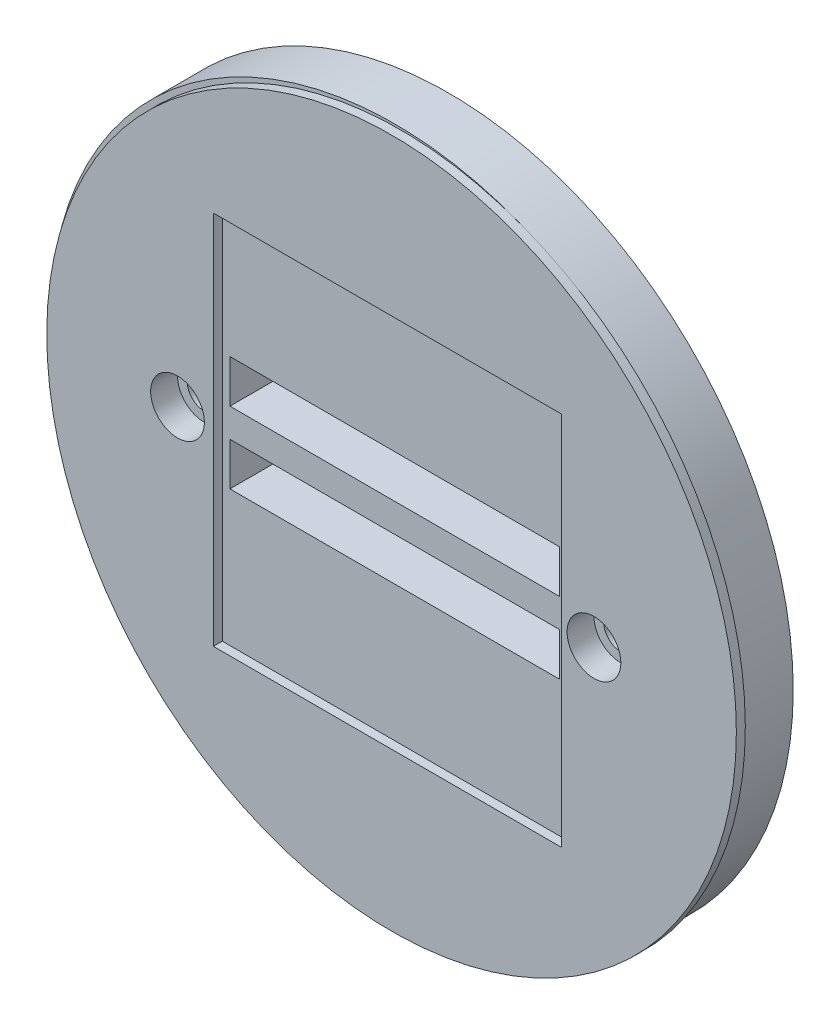
from build123d import *

# Parameters (mm, degrees)
SKETCH1_R                  = 38.5
SKETCH1_R_2                = 1.925
SKETCH1_W                  = 36.8
SKETCH1_H                  = 4.8
MAIN_FLANGE_COUPLING_DEPTH = 6
SKETCH2_R                  = 38.5
SKETCH2_R_2                = 1.7
SKETCH2_W                  = 38.9
SKETCH2_H                  = 41.9
BOSS_EXTRUDE1_DEPTH        = 1
SKETCH3_R                  = 3
CUT_EXTRUDE1_DEPTH         = 3


with BuildPart() as part:
    # Sketch1 → Main Flange Coupling (new body)
    with BuildSketch(Plane.XY):
        Circle(SKETCH1_R)
        with Locations((-23.25, 0)):
            Circle(SKETCH1_R_2, mode=Mode.SUBTRACT)
        with Locations((23.25, 0)):
            Circle(SKETCH1_R_2, mode=Mode.SUBTRACT)
        with Locations((0, 4.4)):
            Rectangle(SKETCH1_W, SKETCH1_H, mode=Mode.SUBTRACT)
        with Locations((0, -3.6)):
            Rectangle(SKETCH1_W, SKETCH1_H, mode=Mode.SUBTRACT)
    extrude(amount=-MAIN_FLANGE_COUPLING_DEPTH)

    # Sketch2 → Boss-Extrude1 (add)
    with BuildSketch(Plane.XY):
        with Locations((0.65, -0.25)):
            Circle(SKETCH2_R)
        with Locations((-23.25, 0)):
            Circle(SKETCH2_R_2, mode=Mode.SUBTRACT)
        with Locations((23.25, 0)):
            Circle(SKETCH2_R_2, mode=Mode.SUBTRACT)
        with Locations((0.2, -0.2)):
            Rectangle(SKETCH2_W, SKETCH2_H, mode=Mode.SUBTRACT)
    extrude(amount=BOSS_EXTRUDE1_DEPTH)

    # Sketch3 → Cut-Extrude1 (cut)
    with BuildSketch(Plane.XY.offset(1)):
        with Locations((-23.25, 0)):
            Circle(SKETCH3_R)
        with Locations((23.25, 0)):
            Circle(SKETCH3_R)
    extrude(amount=-CUT_EXTRUDE1_DEPTH, mode=Mode.SUBTRACT)


solid = part.part
